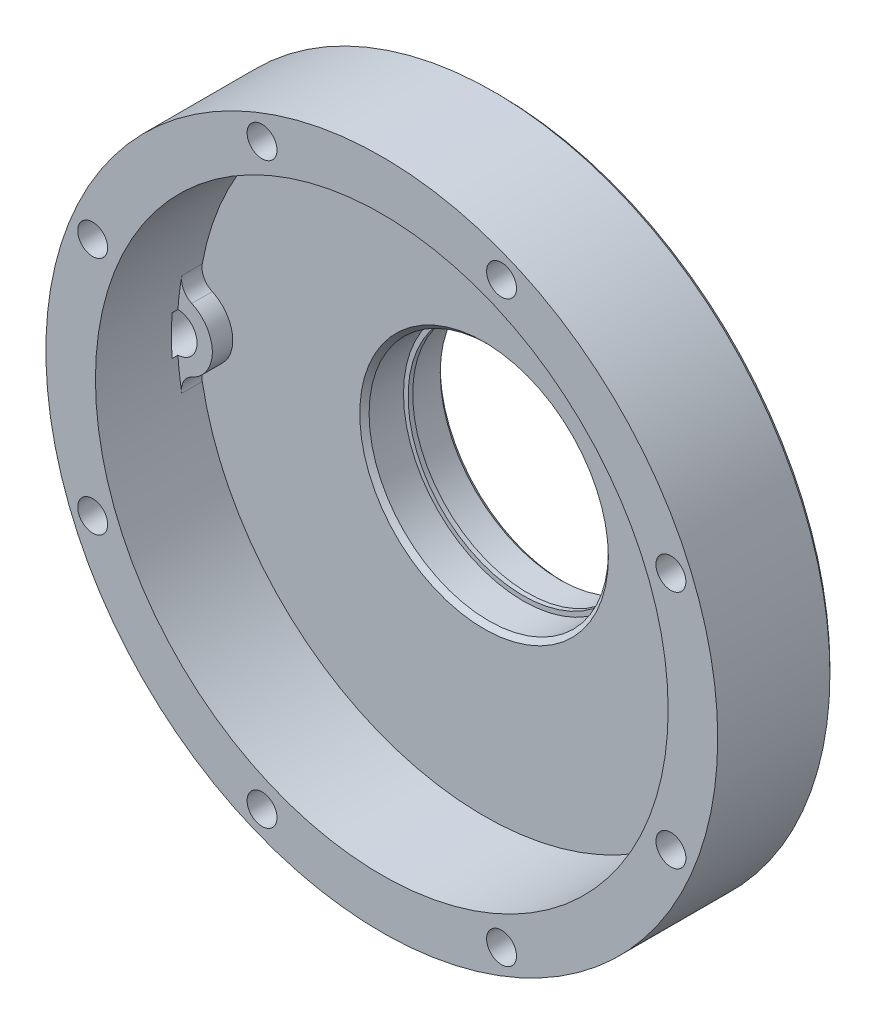
from build123d import *

# Parameters (mm, degrees)
SKETCH2_W               = 4.445
SKETCH2_H               = 7.62
PLANETARY_PLATE_R       = 3.25
CUT_EXTRUDE2_DEPTH      = 7.107467815
CUT_EXTRUDE2_DEPTH_BACK = 34.605032185
SKETCH3_R               = 4.3053
CUT_EXTRUDE3_DEPTH      = 8.89
CUT_EXTRUDE4_DEPTH      = 4.445


with BuildPart() as part:
    # Sketch2 → Revolve1 (revolve)
    with BuildSketch(Plane(origin=(0, 0, 0), x_dir=(0, 0, -1), z_dir=(1, 0, 0))):
        with BuildLine():
            Line((18.276532185, 73), (-6.107467815, 73))
            Line((-6.107467815, 73), (-6.107467815, 62.23))
            Line((-6.107467815, 62.23), (11.672532185, 62.23))
            Line((11.672532185, 62.23), (16.117532185, 62.23))
            Line((16.117532185, 62.23), (16.117532185, 54.61))
            Line((16.117532185, 54.61), (16.117532185, 27.016))
            Line((16.117532185, 27.016), (17.133532185, 26))
            Line((17.133532185, 26), (24.605032185, 26))
            Line((24.605032185, 26), (24.605032185, 25))
            Line((24.605032185, 25), (25.605032185, 25))
            Line((25.605032185, 25), (25.605032185, 26))
            Line((25.605032185, 26), (32.589032185, 26))
            Line((32.589032185, 26), (33.605032185, 27.016))
            Line((33.605032185, 27.016), (33.605032185, 31.334))
            Line((33.605032185, 31.334), (32.589032185, 32.35))
            Line((32.589032185, 32.35), (22.467532185, 32.35))
            ThreePointArc((22.467532185, 32.35), (20.222468154, 33.27993597), (19.292532185, 35.525))
            Line((19.292532185, 35.525), (19.292532185, 71.984))
            Line((19.292532185, 71.984), (18.276532185, 73))
        make_face()
        with Locations((13.895032185, 58.42)):
            Rectangle(SKETCH2_W, SKETCH2_H)
    revolve(axis=Axis((0, 0, 0), (0, 0, -1)))

    # Planetary Plate → Cut-Extrude2 (cut, two sides)
    with BuildSketch(Plane.XY) as cut_extrude2_sk:
        with Locations((26.022473401, 62.823808211)):
            Circle(PLANETARY_PLATE_R)
        with Locations((62.823808211, 26.022473401)):
            Circle(PLANETARY_PLATE_R)
        with Locations((62.823808211, -26.022473401)):
            Circle(PLANETARY_PLATE_R)
        with Locations((26.022473401, -62.823808211)):
            Circle(PLANETARY_PLATE_R)
        with Locations((-26.022473401, -62.823808211)):
            Circle(PLANETARY_PLATE_R)
        with Locations((-62.823808211, -26.022473401)):
            Circle(PLANETARY_PLATE_R)
        with Locations((-62.823808211, 26.022473401)):
            Circle(PLANETARY_PLATE_R)
        with Locations((-26.022473401, 62.823808211)):
            Circle(PLANETARY_PLATE_R)
    extrude(amount=CUT_EXTRUDE2_DEPTH, mode=Mode.SUBTRACT)
    extrude(cut_extrude2_sk.sketch, amount=-CUT_EXTRUDE2_DEPTH_BACK, mode=Mode.SUBTRACT)

    # Sketch3 → Cut-Extrude3 (cut)
    with BuildSketch(Plane(origin=(0, 0, -19.292532185), x_dir=(-1, 0, 0), z_dir=(0, 0, -1))):
        with Locations((0, 62.23)):
            Circle(SKETCH3_R)
        with Locations((62.23, 0)):
            Circle(SKETCH3_R)
    extrude(amount=-CUT_EXTRUDE3_DEPTH, mode=Mode.SUBTRACT)

    # Sketch5 → Cut-Extrude4 (cut)
    with BuildSketch(Plane.XY.offset(-11.672532185)):
        with BuildLine():
            ThreePointArc((-6.932957369, 59.067959184), (-8.633427721, 60.862929677), (-11.077660143, 61.236086957))
            ThreePointArc((-11.077660143, 61.236086957), (-44.003254993, 44.003254993), (-61.236086957, 11.077660143))
            ThreePointArc((-61.236086957, 11.077660143), (-60.862929677, 8.633427721), (-59.067959184, 6.932957369))
            ThreePointArc((-59.067959184, 6.932957369), (-55.820664951, 4.121264882), (-54.61, -7.6e-08))
            ThreePointArc((-54.61, -7.6e-08), (-38.615101322, 38.61510132), (7.3e-08, 54.61))
            ThreePointArc((7.3e-08, 54.61), (-4.121264883, 55.820664952), (-6.932957369, 59.067959184))
        make_face()
        with BuildLine():
            ThreePointArc((6.932957369, 59.067959184), (4.121264944, 55.820664991), (7.3e-08, 54.61))
            ThreePointArc((7.3e-08, 54.61), (38.615101322, -38.61510132), (-54.61, -7.6e-08))
            ThreePointArc((-54.61, -7.6e-08), (-55.820664992, -4.121264946), (-59.067959184, -6.932957369))
            ThreePointArc((-59.067959184, -6.932957369), (-60.862929677, -8.633427721), (-61.236086957, -11.077660143))
            ThreePointArc((-61.236086957, -11.077660143), (44.003254993, -44.003254993), (11.077660143, 61.236086957))
            ThreePointArc((11.077660143, 61.236086957), (8.633427721, 60.862929677), (6.932957369, 59.067959184))
        make_face()
    extrude(amount=-CUT_EXTRUDE4_DEPTH, mode=Mode.SUBTRACT)


solid = part.part
